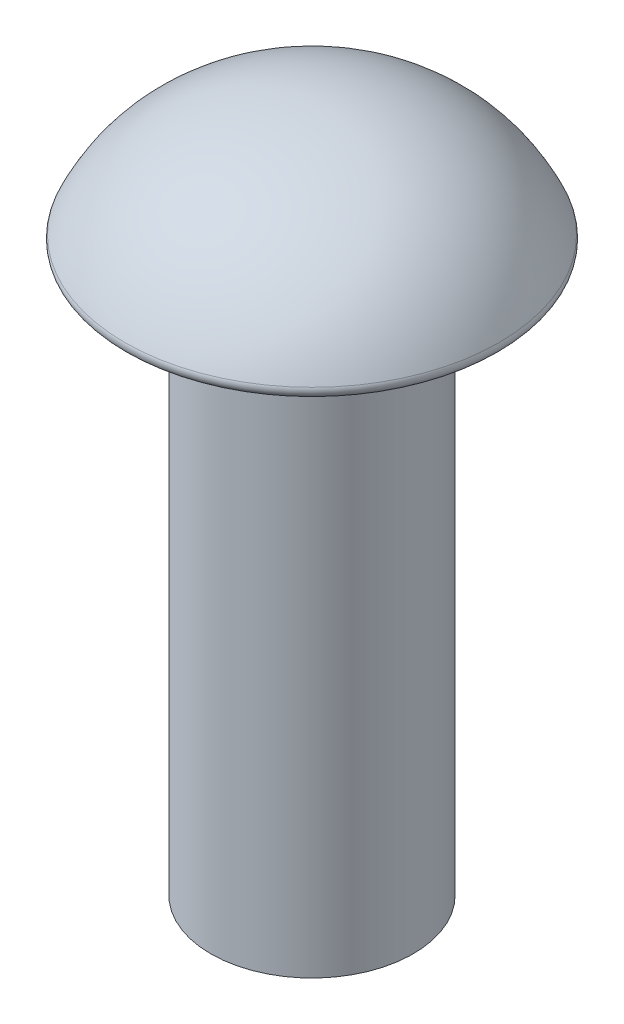
from build123d import *

# Parameters (mm, degrees)
SKETCH1_R           = 2.4
BOSS_EXTRUDE1_DEPTH = 13.3
FILLET1_R           = 0.1905


with BuildPart() as part:
    # Sketch1 → Boss-Extrude1 (new body)
    with BuildSketch(Plane(origin=(0, 0, 0), x_dir=(1, 0, 0), z_dir=(0, 1, 0))):
        Circle(SKETCH1_R)
    extrude(amount=BOSS_EXTRUDE1_DEPTH)

    # Sketch2 → Revolve1 (revolve)
    with BuildSketch(Plane.XY):
        with BuildLine():
            Line((-4.55, 13.3), (0, 13.3))
            Line((0, 13.3), (0, 16.2))
            add(Edge.make_bspline(
                [(0, 16.2), (-1.798533353, 16.2), (-3.716538693, 15.437253148), (-4.55, 13.3)],
                knots=[0, 0, 0, 0, 1, 1, 1, 1], degree=3))
        make_face()
    revolve(axis=Axis((0, 13.3, 0), (0, 1, 0)))

    # Fillet1
    fillet1_edges = [part.edges().sort_by_distance(p)[0] for p in [
        (4.55, 13.3, 0),
    ]]
    fillet(fillet1_edges, radius=FILLET1_R)


solid = part.part
